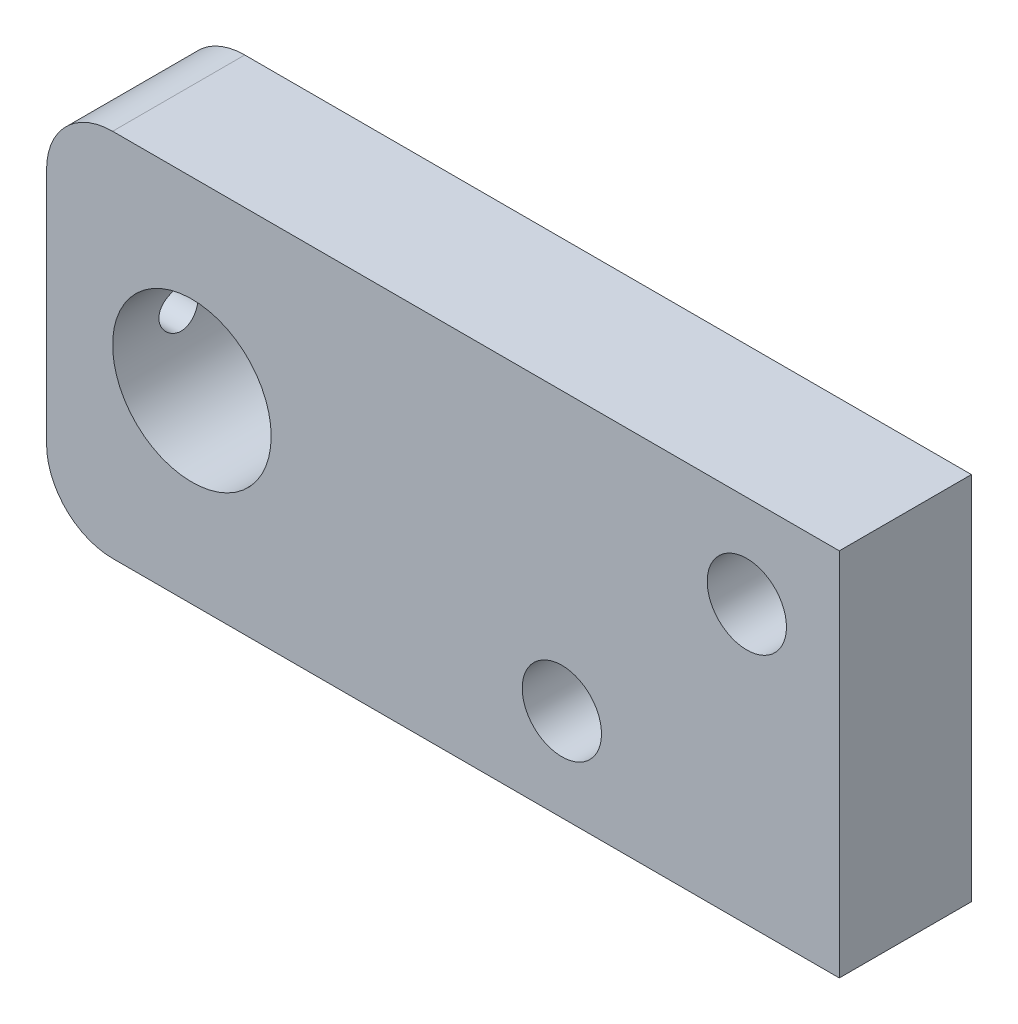
from build123d import *

# Parameters (mm, degrees)
IZIM1_R                     = 3
IZIM1_R_2                   = 6
Y_KSEKLIK_EKSTR_ZYON1_DEPTH = 10
KES_EKSTR_ZYON1_REACH       = 62
IZIM2_R                     = 1.5


with BuildPart() as part:
    # Çizim1 → Yükseklik-Ekstrüzyon1 (new body)
    with BuildSketch(Plane.XY):
        with BuildLine():
            Line((30, -14), (-25, -14))
            ThreePointArc((-25, -14), (-28.535533906, -12.535533906), (-30, -9))
            Line((-30, -9), (-30, 9))
            ThreePointArc((-30, 9), (-28.535533906, 12.535533906), (-25, 14))
            Line((-25, 14), (30, 14))
            Line((30, 14), (30, -14))
        make_face()
        with Locations((23, 7)):
            Circle(IZIM1_R, mode=Mode.SUBTRACT)
        with Locations((-19, 0)):
            Circle(IZIM1_R_2, mode=Mode.SUBTRACT)
        with Locations((9, -7)):
            Circle(IZIM1_R, mode=Mode.SUBTRACT)
    extrude(amount=Y_KSEKLIK_EKSTR_ZYON1_DEPTH)

    # Çizim2 → Kes-Ekstrüzyon1 (cut, up to next)
    with BuildSketch(Plane.ZY.offset(30), mode=Mode.PRIVATE) as kes_ekstr_zyon1_sk1:
        with Locations((5, 0)):
            Circle(IZIM2_R)
    kes_ekstr_zyon1_tool1 = extrude(kes_ekstr_zyon1_sk1.sketch, amount=-KES_EKSTR_ZYON1_REACH, mode=Mode.PRIVATE) & part.part
    add(kes_ekstr_zyon1_tool1.solids().sort_by_distance((-30, 0, 5))[0], mode=Mode.SUBTRACT)


solid = part.part
